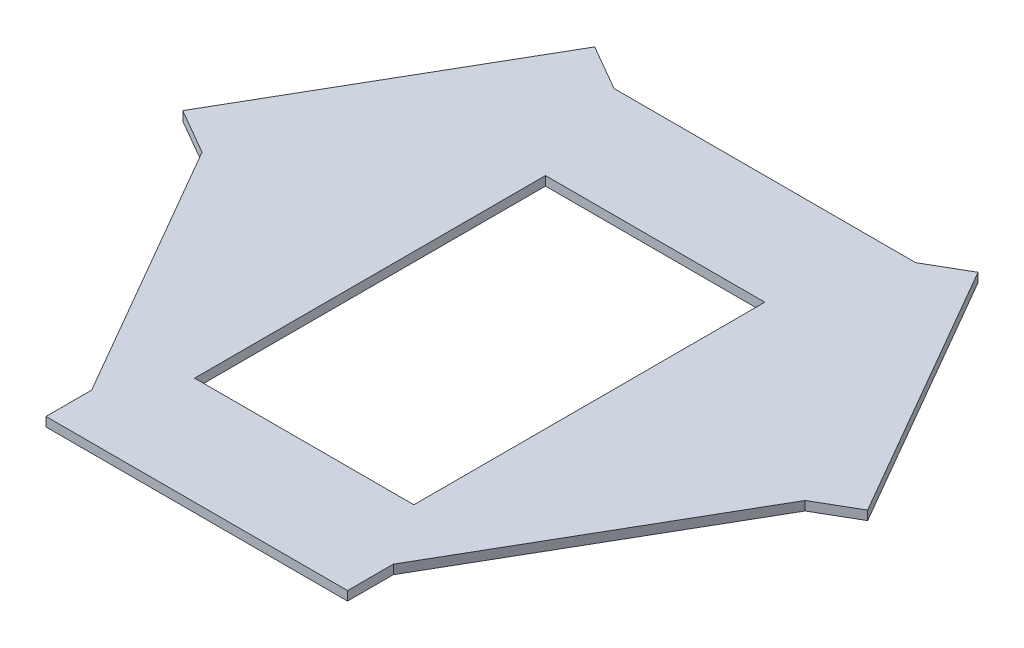
from build123d import *

# Parameters (mm, degrees)
SKETCH1_W           = 120
SKETCH1_H           = 192
SKETCH1_W_2         = 165
SKETCH1_H_2         = 25
BOSS_EXTRUDE2_DEPTH = 5


with BuildPart() as part:
    # Sketch1 → Boss-Extrude2 (new body)
    with BuildSketch(Plane(origin=(0, 0, 0), x_dir=(1, 0, 0), z_dir=(0, 1, 0))):
        Polygon((-165, 0), (-82.5, -142.894191624), (82.5, -142.894191624), (165, 0), (82.5, 142.894191624), (-82.5, 142.894191624), align=None)
        with Locations((0, -13.105808376)):
            Rectangle(SKETCH1_W, SKETCH1_H, mode=Mode.SUBTRACT)
        Polygon((-82.5, 142.894191624), (-107.5, 157.327948354), (-190, 14.43375673), (-165, 0), align=None)
        Polygon((104.150635095, 155.394191624), (186.650635095, 12.5), (165, 0), (82.5, 142.894191624), align=None)
        with Locations((0, -155.394191624)):
            Rectangle(SKETCH1_W_2, SKETCH1_H_2)
    extrude(amount=BOSS_EXTRUDE2_DEPTH)


solid = part.part
